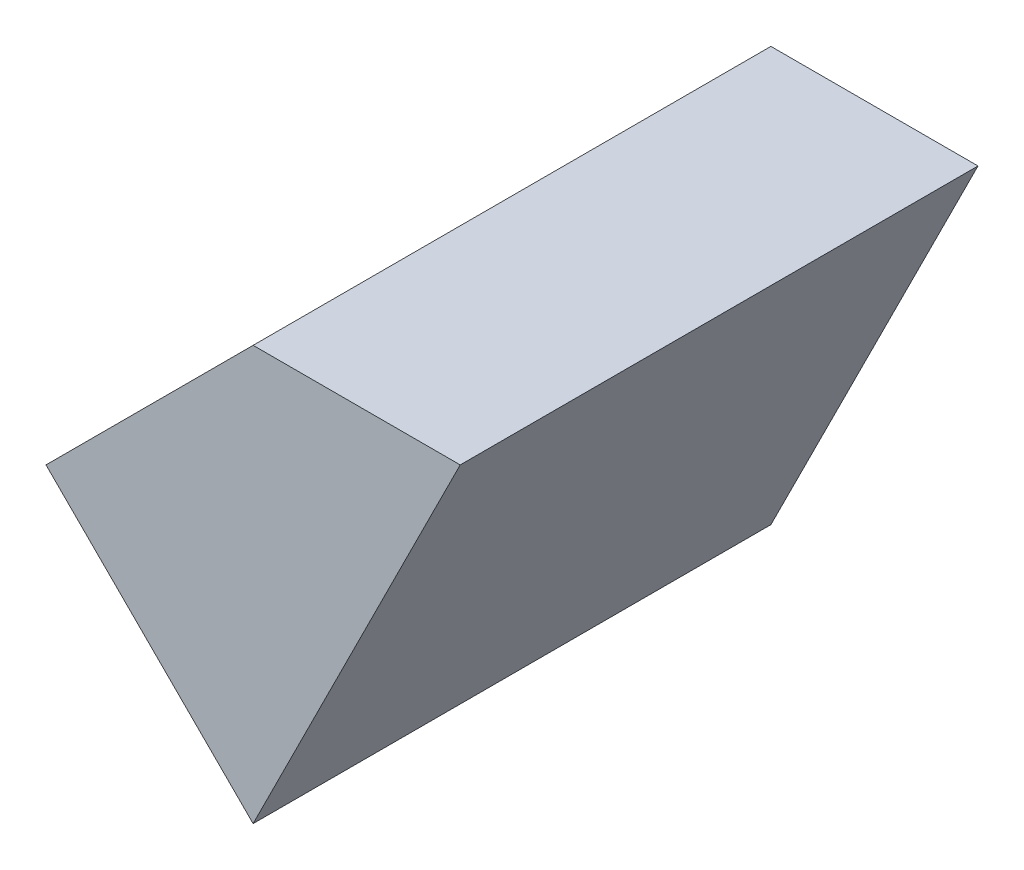
from build123d import *

# Parameters (mm, degrees)
BOSS_EXTRUDE1_DEPTH = 25


with BuildPart() as part:
    # Sketch1 → Boss-Extrude1 (new body)
    with BuildSketch(Plane.XY):
        Polygon((0, 0), (10, 0), (0, -20), (-10, -10), align=None)
    extrude(amount=BOSS_EXTRUDE1_DEPTH)


solid = part.part
